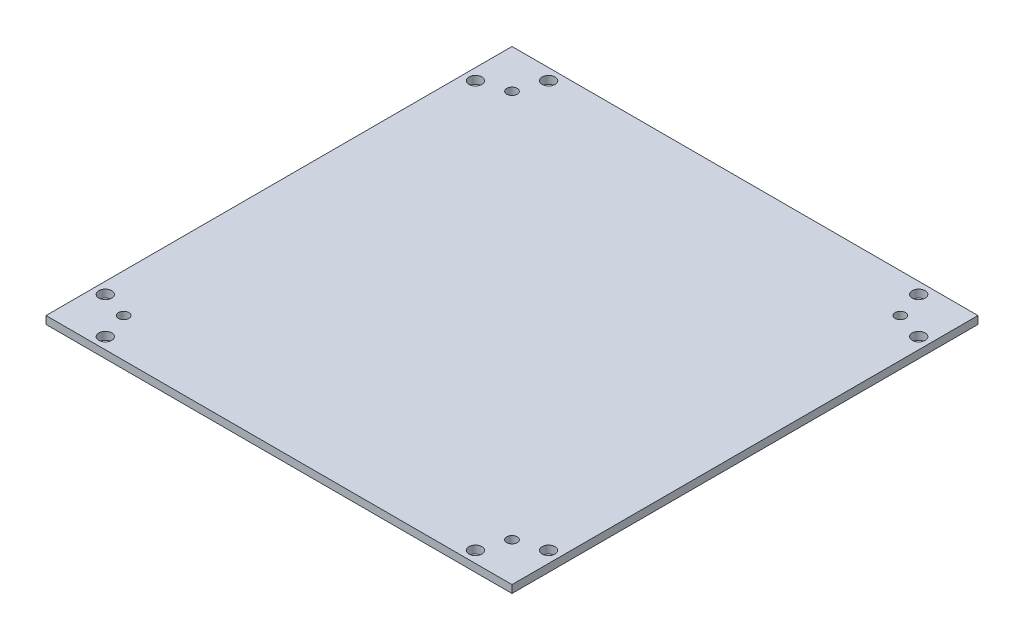
from build123d import *

# Parameters (mm, degrees)
SKETCH1_W           = 180
SKETCH1_H           = 180
SKETCH1_R           = 2
SKETCH1_R_2         = 2.5
BOSS_EXTRUDE1_DEPTH = 3


with BuildPart() as part:
    # Sketch1 → Boss-Extrude1 (new body)
    with BuildSketch(Plane(origin=(0, 0, 0), x_dir=(1, 0, 0), z_dir=(0, 1, 0))):
        Rectangle(SKETCH1_W, SKETCH1_H)
        with Locations((-75, 75)):
            Circle(SKETCH1_R, mode=Mode.SUBTRACT)
        with Locations((75, 75)):
            Circle(SKETCH1_R, mode=Mode.SUBTRACT)
        with Locations((-75, -75)):
            Circle(SKETCH1_R, mode=Mode.SUBTRACT)
        with Locations((75, -75)):
            Circle(SKETCH1_R, mode=Mode.SUBTRACT)
        with Locations((-85.62, 71.48)):
            Circle(SKETCH1_R_2, mode=Mode.SUBTRACT)
        with Locations((-71.477864376, 85.622135624)):
            Circle(SKETCH1_R_2, mode=Mode.SUBTRACT)
        with Locations((85.622135624, 71.477864376)):
            Circle(SKETCH1_R_2, mode=Mode.SUBTRACT)
        with Locations((71.48, 85.62)):
            Circle(SKETCH1_R_2, mode=Mode.SUBTRACT)
        with Locations((71.477864376, -85.622135624)):
            Circle(SKETCH1_R_2, mode=Mode.SUBTRACT)
        with Locations((85.62, -71.48)):
            Circle(SKETCH1_R_2, mode=Mode.SUBTRACT)
        with Locations((-85.622135624, -71.477864376)):
            Circle(SKETCH1_R_2, mode=Mode.SUBTRACT)
        with Locations((-71.48, -85.62)):
            Circle(SKETCH1_R_2, mode=Mode.SUBTRACT)
    extrude(amount=BOSS_EXTRUDE1_DEPTH)


solid = part.part
